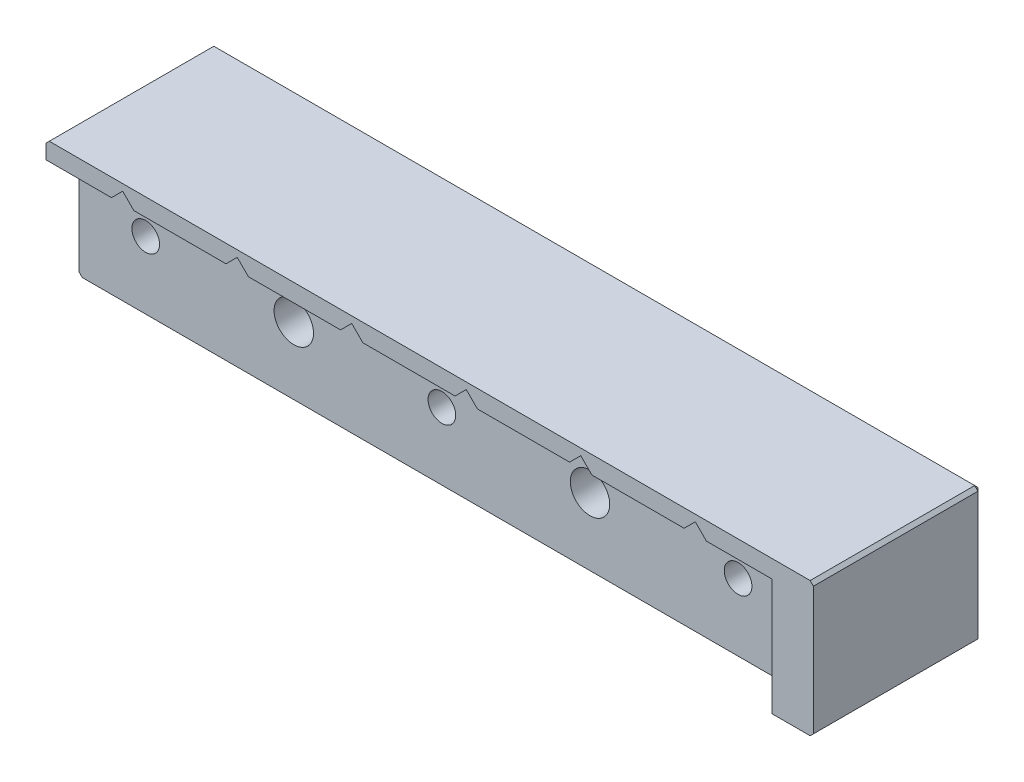
from build123d import *

# Parameters (mm, degrees)
SKETCH_2_W          = 116.6
SKETCH_2_H          = 20.43
EXTRUDE_1_DEPTH     = 25.5
CUT_EXTRUDE_1_DEPTH = 5
M5X0_81_D           = 4.2
HOLE_WIZARD_6_0_1_D = 6
CHAMFER_1_SIZE      = 0.5


with BuildPart() as part:
    # Эскиз2 → Бобышка-Вытянуть1 (new body)
    with BuildSketch(Plane.XY):
        with Locations((58.3, 10.215)):
            Rectangle(SKETCH_2_W, SKETCH_2_H)
    extrude(amount=-EXTRUDE_1_DEPTH)

    # Эскиз1 → Вырез-Вытянуть1 (cut)
    with BuildSketch(Plane.XY):
        Polygon((27.35, 17.73), (29.05, 19.43), (30.75, 17.73), (44.75, 17.73), (46.45, 19.43), (48.15, 17.73), (62.15, 17.73), (63.85, 19.43), (65.55, 17.73), (79.55, 17.73), (81.25, 19.43), (82.95, 17.73), (96.95, 17.73), (98.65, 19.43), (100.35, 17.73), (110.3, 17.73), (110.3, 0), (0, 0), (0, 17.73), (9.95, 17.73), (11.65, 19.43), (13.35, 17.73), align=None)
    extrude(amount=-CUT_EXTRUDE_1_DEPTH, mode=Mode.SUBTRACT)

    # Отверстие обработанное метчиком M5x0.81 (through all)
    with Locations(Plane(origin=(-38.872854219, 5.478694599, -5), x_dir=(1, 0, 0), z_dir=(0, 0, 1))):
        with Locations((94.022854219, 4.751305401), (49.022854219, 4.751305401), (139.022854219, 4.751305401)):
            Hole(M5X0_81_D / 2)

    # Отверстия под штифты Ø6.0 мм1 (through all)
    with Locations(Plane.XY.offset(-5)):
        with Locations((32.65, 10.23), (77.65, 10.23)):
            Hole(HOLE_WIZARD_6_0_1_D / 2)

    # Фаска1
    chamfer_1_edges = [part.edges().sort_by_distance(p)[0] for p in [
        (116.6, 10.215, -25.5),
        (58.3, 20.43, -25.5),
        (0, 10.215, -25.5),
        (58.3, 0, -25.5),
        (0, 20.43, -12.75),
        (116.6, 20.43, -12.75),
        (116.6, 0, -12.75),
        (0, 0, -15.25),
    ]]
    chamfer(chamfer_1_edges, length=CHAMFER_1_SIZE)


solid = part.part
